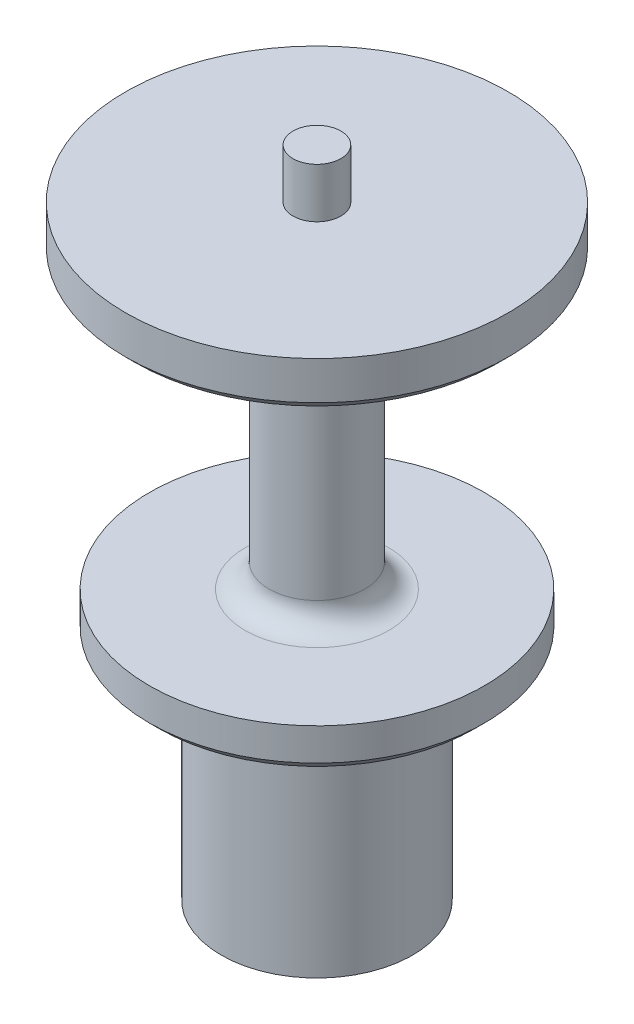
from build123d import *

# Parameters (mm, degrees)
SKETCH1_R           = 12.7
BOSS_EXTRUDE1_DEPTH = 30.1625
SKETCH4_R           = 25.4
BOSS_EXTRUDE2_DEPTH = 50.00625
CUT_EXTRUDE1_DEPTH  = 11.176
SKETCH3_R           = 6
CUT_EXTRUDE2_DEPTH  = 8
SKETCH5_R           = 3.175
BOSS_EXTRUDE3_DEPTH = 6.604
CUT_EXTRUDE3_START  = -6.35
SKETCH9_R           = 25.4
SKETCH9_R_2         = 6.35
CUT_EXTRUDE3_DEPTH  = 38.1
CUT_EXTRUDE4_REACH  = 58.61
SKETCH10_R          = 25.4
SKETCH10_R_2        = 22.225
FILLET1_R           = 3.175
CHAMFER1_SIZE       = 1.27


with BuildPart() as part:
    # Sketch1 → Boss-Extrude1 (new body)
    with BuildSketch(Plane(origin=(0, 0, 0), x_dir=(1, 0, 0), z_dir=(0, 1, 0))):
        Circle(SKETCH1_R)
    extrude(amount=BOSS_EXTRUDE1_DEPTH)

    # Sketch4 → Boss-Extrude2 (add)
    with BuildSketch(Plane(origin=(0, 30.1625, 0), x_dir=(1, 0, 0), z_dir=(0, 1, 0))):
        Circle(SKETCH4_R)
    extrude(amount=BOSS_EXTRUDE2_DEPTH)

    # Sketch2 → Cut-Extrude1 (cut)
    with BuildSketch(Plane.XZ):
        with BuildLine():
            Line((-7, 2.899494937), (-8.776962921, 1.122532015))
            ThreePointArc((-8.776962921, 1.122532015), (-9.241930906, 0), (-8.776962921, -1.122532015))
            Line((-8.776962921, -1.122532015), (-7, -2.899494937))
            Line((-7, -2.899494937), (-7, 2.899494937))
        make_face()
        Polygon((-2.899494937, 7), (-7, 2.899494937), (-7, -2.899494937), (-2.899494937, -7), (2.899494937, -7), (7, -2.899494937), (7, 2.899494937), (2.899494937, 7), align=None)
        with BuildLine():
            Line((-7, 5.4125), (-7, 2.899494937))
            Line((-7, 2.899494937), (-2.899494937, 7))
            Line((-2.899494937, 7), (-5.4125, 7))
            ThreePointArc((-5.4125, 7), (-6.535032015, 6.535032015), (-7, 5.4125))
        make_face()
        with BuildLine():
            Line((-1.122532015, 8.776962921), (-2.899494937, 7))
            Line((-2.899494937, 7), (2.899494937, 7))
            Line((2.899494937, 7), (1.122532015, 8.776962921))
            ThreePointArc((1.122532015, 8.776962921), (0, 9.241930906), (-1.122532015, 8.776962921))
        make_face()
        with BuildLine():
            Line((5.4125, 7), (2.899494937, 7))
            Line((2.899494937, 7), (7, 2.899494937))
            Line((7, 2.899494937), (7, 5.4125))
            ThreePointArc((7, 5.4125), (6.535032015, 6.535032015), (5.4125, 7))
        make_face()
        with BuildLine():
            Line((8.776962921, 1.122532015), (7, 2.899494937))
            Line((7, 2.899494937), (7, -2.899494937))
            Line((7, -2.899494937), (8.776962921, -1.122532015))
            ThreePointArc((8.776962921, -1.122532015), (9.241930906, 0), (8.776962921, 1.122532015))
        make_face()
        with BuildLine():
            Line((7, -2.899494937), (2.899494937, -7))
            Line((2.899494937, -7), (5.4125, -7))
            ThreePointArc((5.4125, -7), (6.535032015, -6.535032015), (7, -5.4125))
            Line((7, -5.4125), (7, -2.899494937))
        make_face()
        with BuildLine():
            Line((2.899494937, -7), (-2.899494937, -7))
            Line((-2.899494937, -7), (-1.122532015, -8.776962921))
            ThreePointArc((-1.122532015, -8.776962921), (0, -9.241930906), (1.122532015, -8.776962921))
            Line((1.122532015, -8.776962921), (2.899494937, -7))
        make_face()
        with BuildLine():
            Line((-2.899494937, -7), (-7, -2.899494937))
            Line((-7, -2.899494937), (-7, -5.4125))
            ThreePointArc((-7, -5.4125), (-6.535032015, -6.535032015), (-5.4125, -7))
            Line((-5.4125, -7), (-2.899494937, -7))
        make_face()
    extrude(amount=-CUT_EXTRUDE1_DEPTH, mode=Mode.SUBTRACT)

    # Sketch3 → Cut-Extrude2 (cut)
    with BuildSketch(Plane.XZ.offset(-11.176)):
        Circle(SKETCH3_R)
    extrude(amount=-CUT_EXTRUDE2_DEPTH, mode=Mode.SUBTRACT)

    # Sketch5 → Boss-Extrude3 (add)
    with BuildSketch(Plane(origin=(0, 80.16875, 0), x_dir=(1, 0, 0), z_dir=(0, 1, 0))):
        Circle(SKETCH5_R)
    extrude(amount=BOSS_EXTRUDE3_DEPTH)

    # Sketch9 → Cut-Extrude3 (cut)
    with BuildSketch(Plane(origin=(0, 80.16875, 0), x_dir=(1, 0, 0), z_dir=(0, 1, 0)).offset(CUT_EXTRUDE3_START)):
        Circle(SKETCH9_R)
        Circle(SKETCH9_R_2, mode=Mode.SUBTRACT)
    extrude(amount=-CUT_EXTRUDE3_DEPTH, mode=Mode.SUBTRACT)

    # Sketch10 → Cut-Extrude4 (cut, up to next)
    with BuildSketch(Plane.XZ.offset(-30.1625), mode=Mode.PRIVATE) as cut_extrude4_sk1:
        Circle(SKETCH10_R)
        Circle(SKETCH10_R_2, mode=Mode.SUBTRACT)
    cut_extrude4_tool1 = extrude(cut_extrude4_sk1.sketch, amount=-CUT_EXTRUDE4_REACH, mode=Mode.PRIVATE) & part.part
    add(cut_extrude4_tool1.solids().sort_by_distance((-24.68158, 30.1625, 0))[0], mode=Mode.SUBTRACT)

    # Fillet1
    fillet1_edges = [part.edges().sort_by_distance(p)[0] for p in [
        (-6.35, 35.71875, 0),
        (-6.35, 73.81875, 0),
    ]]
    fillet(fillet1_edges, radius=FILLET1_R)

    # Chamfer1
    chamfer1_edges = [part.edges().sort_by_distance(p)[0] for p in [
        (-25.4, 73.81875, 0),
        (-22.225, 30.1625, 0),
    ]]
    chamfer(chamfer1_edges, length=CHAMFER1_SIZE)


solid = part.part
